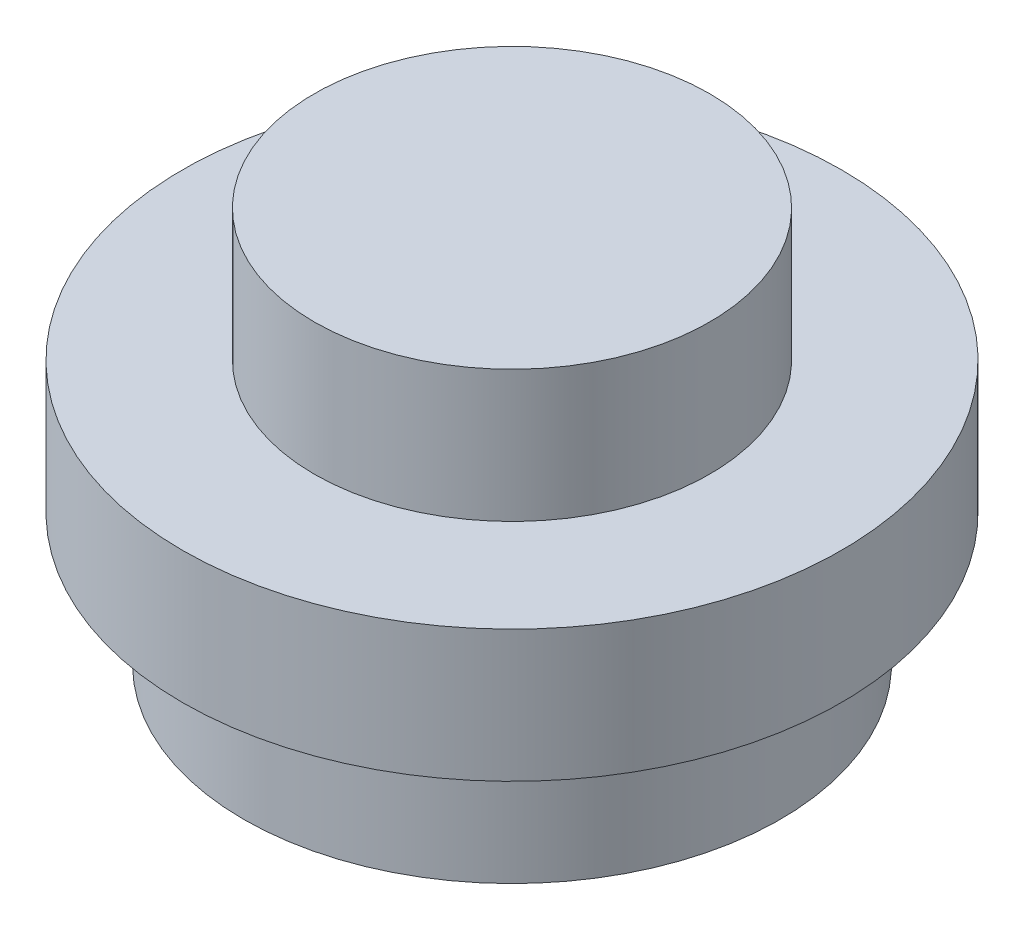
from build123d import *

# Parameters (mm, degrees)
SKETCH1_R           = 1.5
BOSS_EXTRUDE1_DEPTH = 2
SKETCH1_3_R         = 2.035533906
SKETCH1_3_R_2       = 1.5
BOSS_EXTRUDE2_DEPTH = 1
SKETCH1_4_R         = 2.5
BOSS_EXTRUDE3_DEPTH = 1
SKETCH2_R           = 0.75
CUT_EXTRUDE1_DEPTH  = 1


with BuildPart() as part:
    # Sketch1 → Boss-Extrude1 (new body)
    with BuildSketch(Plane(origin=(0, 0, 0), x_dir=(1, 0, 0), z_dir=(0, 1, 0))):
        Circle(SKETCH1_R)
    extrude(amount=BOSS_EXTRUDE1_DEPTH)



with BuildPart() as body_2:
    # Sketch1_3 → Boss-Extrude2 (new body)
    with BuildSketch(Plane(origin=(0, 0, 0), x_dir=(1, 0, 0), z_dir=(0, 1, 0))):
        Circle(SKETCH1_3_R)
        Circle(SKETCH1_3_R_2, mode=Mode.SUBTRACT)
    extrude(amount=-BOSS_EXTRUDE2_DEPTH)


with BuildPart() as part_1:
    add(part.part)

    add(body_2.part)  # Boss-Extrude3 merges body 2
    # Sketch1_4 → Boss-Extrude3 (add)
    with BuildSketch(Plane(origin=(0, 0, 0), x_dir=(1, 0, 0), z_dir=(0, 1, 0))):
        Circle(SKETCH1_4_R)
    extrude(amount=BOSS_EXTRUDE3_DEPTH)

    # Sketch2 → Cut-Extrude1 (cut)
    with BuildSketch(Plane(origin=(0, 0, 0), x_dir=(-1, 0, 0), z_dir=(0, -1, 0))):
        Circle(SKETCH2_R)
    extrude(amount=-CUT_EXTRUDE1_DEPTH, mode=Mode.SUBTRACT)


solid = part_1.part
